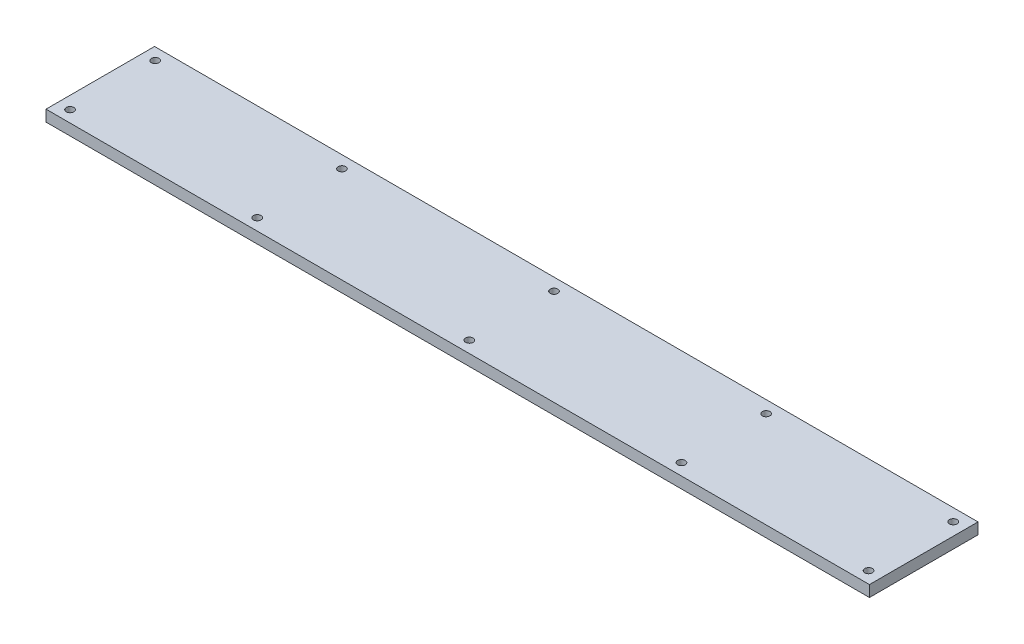
from build123d import *

# Parameters (mm, degrees)
SKETCH1_W                  = 330
SKETCH1_H                  = 43.5
BOSS_EXTRUDE1_DEPTH        = 4.5
F_31_0_12_DIAMETER_HOLE3_D = 3.048


with BuildPart() as part:
    # Sketch1 → Boss-Extrude1 (new body)
    with BuildSketch(Plane(origin=(0, 0, 0), x_dir=(1, 0, 0), z_dir=(0, 1, 0))):
        with Locations((-165, 21.75)):
            Rectangle(SKETCH1_W, SKETCH1_H)
    extrude(amount=BOSS_EXTRUDE1_DEPTH)

    # #31 (0.12) Diameter Hole3 (through all)
    with Locations(Plane(origin=(0, 4.5, 0), x_dir=(1, 0, 0), z_dir=(0, 1, 0))):
        with Locations((-325, 38.75), (-325, 4.64300545), (-250, 4.64300545), (-250, 38.591771868), (-165, 38.591771868), (-165, 4.64300545), (-80, 4.64300545), (-80, 38.591771868), (-5, 38.591771868), (-5, 4.64300545)):
            Hole(F_31_0_12_DIAMETER_HOLE3_D / 2)


solid = part.part
